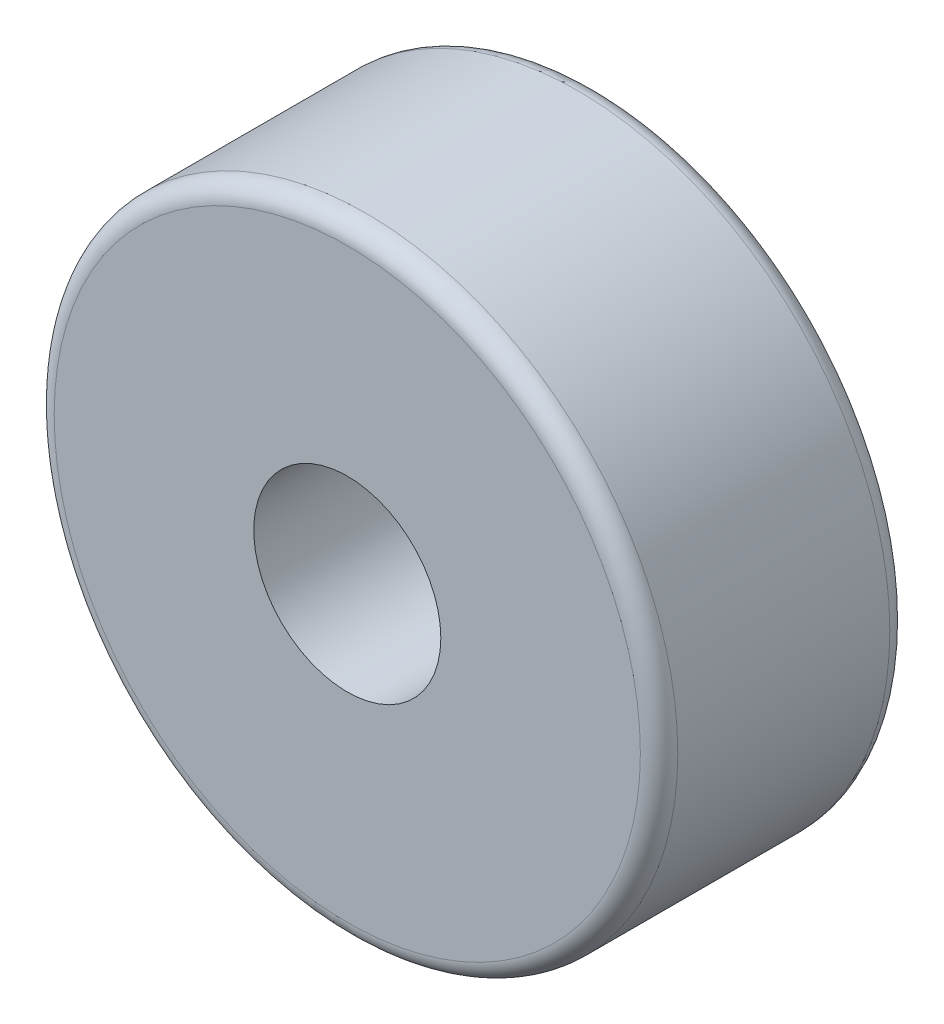
from build123d import *

# Parameters (mm, degrees)
SKETCH1_R           = 5
SKETCH1_R_2         = 1.5
BOSS_EXTRUDE1_DEPTH = 4
FILLET1_R           = 0.3


with BuildPart() as part:
    # Sketch1 → Boss-Extrude1 (new body)
    with BuildSketch(Plane.XY):
        Circle(SKETCH1_R)
        Circle(SKETCH1_R_2, mode=Mode.SUBTRACT)
    extrude(amount=BOSS_EXTRUDE1_DEPTH)

    # Fillet1
    fillet1_edges = [part.edges().sort_by_distance(p)[0] for p in [
        (-5, 0, 0),
        (-5, 0, 4),
    ]]
    fillet(fillet1_edges, radius=FILLET1_R)


solid = part.part
